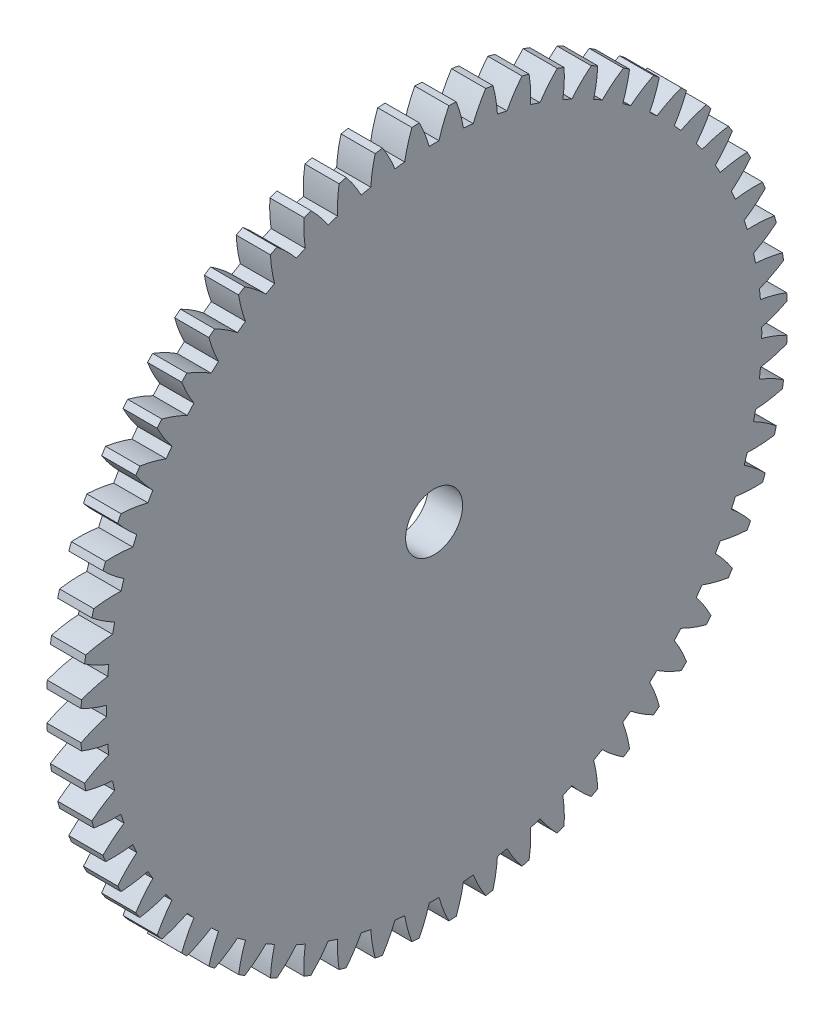
from build123d import *

# Parameters (mm, degrees)
BASPROSKE_W     = 3
BASPROSKE_H     = 31
TOOTHCUT_DEPTH  = 44.943145085
TEETHCUTS_COUNT = 60
TEETHCUTS_ANGLE = 354
BORSKE_R        = 2.5
BORE_DEPTH      = 50.0000508


with BuildPart() as part:
    # BasProSke → Base-Revolve (revolve)
    with BuildSketch(Plane(origin=(0, 0, 0), x_dir=(1, 0, 0), z_dir=(0, 1, 0)), mode=Mode.PRIVATE) as base_revolve_sk:
        with Locations((1.5, 15.5)):
            Rectangle(BASPROSKE_W, BASPROSKE_H)
    revolve(base_revolve_sk.sketch.rotate(Axis((-10, 0, 0), (1, 0, 0)), 180), axis=Axis((-10, 0, 0), (1, 0, 0)))

    # TooCutSke → ToothCut (cut, through all)
    with BuildSketch(Plane(origin=(0, 0, 0), x_dir=(0, 0, -1), z_dir=(1, 0, 0))):
        with BuildLine():
            ThreePointArc((0.430151971, 28.745781782), (0, 28.749), (-0.430151971, 28.745781782))
            ThreePointArc((-0.430151971, 28.745781782), (-0.81454129, 29.893990802), (-1.312684569, 30.997617721))
            ThreePointArc((-1.312684569, 30.997617721), (0, 31.0254), (1.312684569, 30.997617721))
            ThreePointArc((1.312684569, 30.997617721), (0.81454129, 29.893990802), (0.430151971, 28.745781782))
        make_face()
    toothcut = extrude(amount=TOOTHCUT_DEPTH, mode=Mode.SUBTRACT)

    # TeethCuts: ToothCut ×60 about axis
    teethcuts_axis = Axis((-10, 0, 0), (1, 0, 0))
    for i in range(1, TEETHCUTS_COUNT):
        add(toothcut.rotate(teethcuts_axis, i * TEETHCUTS_ANGLE / (TEETHCUTS_COUNT - 1)), mode=Mode.SUBTRACT)

    # BorSke → Bore (cut, symmetric)
    with BuildSketch(Plane(origin=(0, 0, 0), x_dir=(0, 0, -1), z_dir=(1, 0, 0))):
        with Locations(Location((0, 0, 0), (0, 0, 180))):
            Circle(BORSKE_R)
    extrude(amount=BORE_DEPTH, both=True, mode=Mode.SUBTRACT)


solid = part.part
